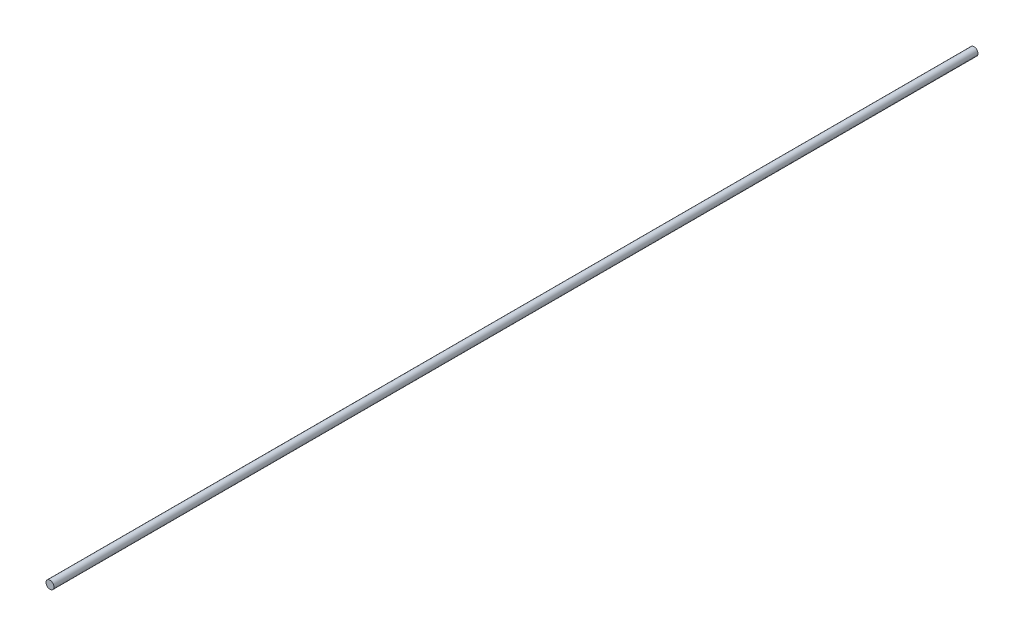
from build123d import *

# Parameters (mm, degrees)
SKETCH1_R           = 4
BOSS_EXTRUDE1_DEPTH = 930


with BuildPart() as part:
    # Sketch1 → Boss-Extrude1 (new body)
    with BuildSketch(Plane.XY):
        Circle(SKETCH1_R)
    extrude(amount=BOSS_EXTRUDE1_DEPTH)


solid = part.part
